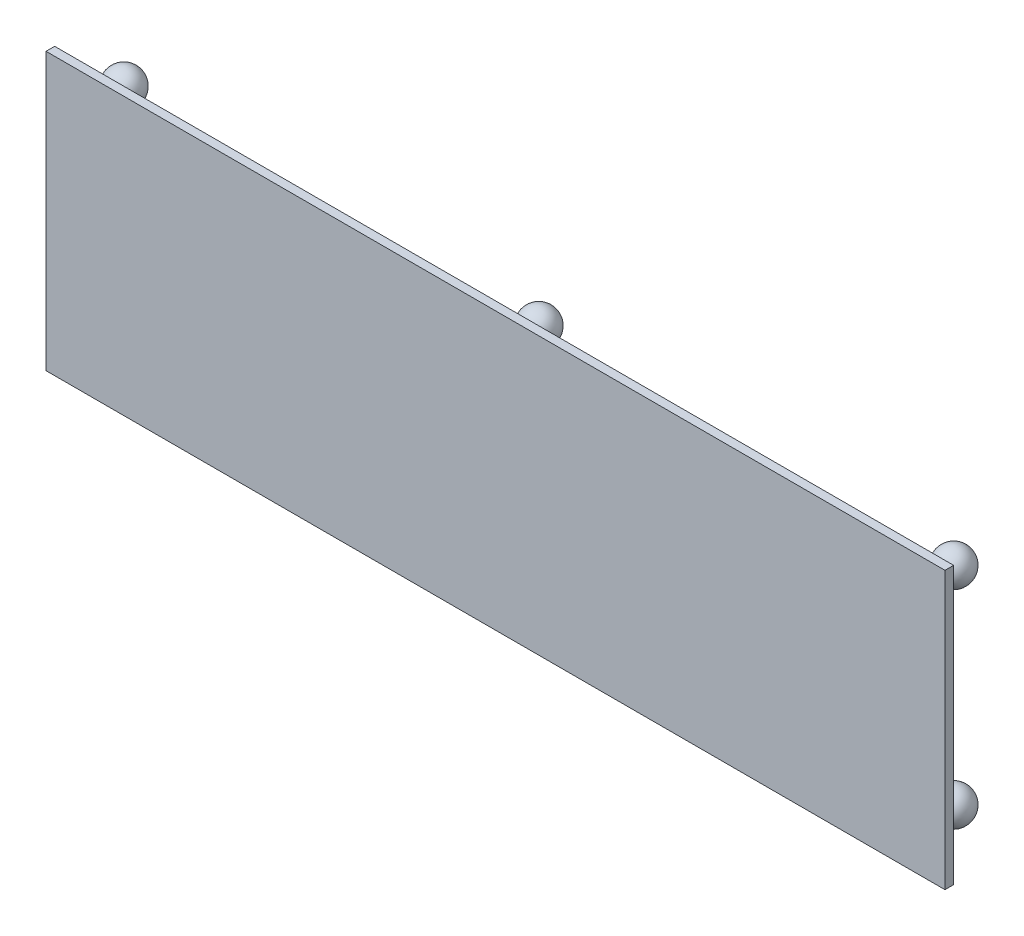
from build123d import *

# Parameters (mm, degrees)
SKETCH1_W           = 660.4
SKETCH1_H           = 203.2
BOSS_EXTRUDE1_DEPTH = 6.35
LPATTERN1_COUNT     = 2
LPATTERN1_PITCH     = 304.8
LPATTERN1_COL_COUNT = 2
LPATTERN1_COL_PITCH = 304.8


with BuildPart() as part:
    # Sketch1 → Boss-Extrude1 (new body)
    with BuildSketch(Plane.XY):
        Rectangle(SKETCH1_W, SKETCH1_H)
    extrude(amount=BOSS_EXTRUDE1_DEPTH)

    # Sketch3 → Revolve1 (revolve)
    with BuildSketch(Plane(origin=(0, 0, 0), x_dir=(0, 0, -1), z_dir=(1, 0, 0))):
        with BuildLine():
            Line((0, -76.2), (38.1, -76.2))
            ThreePointArc((38.1, -76.2), (28.44332506, -88.529970502), (14.158555499, -82.10930838))
            Line((14.158555499, -82.10930838), (0, -82.10930838))
            Line((0, -82.10930838), (0, -76.2))
        make_face()
    revolve1 = revolve(axis=Axis((0, -76.2, 0), (0, 0, -1)))

    # Mirror1: Revolve1 across plane
    add(revolve1.mirror(Plane.ZX))

    # LPattern1: Revolve1 ×2
    with Locations(*[(i * LPATTERN1_PITCH, 0, 0) for i in range(1, LPATTERN1_COUNT)]):
        add(revolve1)

    # LPattern1 copy 1 sketch → LPattern1 copy 1 (revolve)
    with BuildSketch(Plane(origin=(304.8, 0, 0), x_dir=(0, 0, -1), z_dir=(1, 0, 0))):
        with BuildLine():
            Line((0, 76.2), (38.1, 76.2))
            ThreePointArc((38.1, 76.2), (28.44332506, 88.529970502), (14.158555499, 82.10930838))
            Line((14.158555499, 82.10930838), (0, 82.10930838))
            Line((0, 82.10930838), (0, 76.2))
        make_face()
    revolve(axis=Axis((304.8, 76.2, 0), (0, 0, 1)))

    # LPattern1 col: Revolve1 ×2
    with Locations(*[(-i * LPATTERN1_COL_PITCH, 0, 0) for i in range(1, LPATTERN1_COL_COUNT)]):
        add(revolve1)

    # LPattern1 col copy 1 sketch → LPattern1 col copy 1 (revolve)
    with BuildSketch(Plane(origin=(-304.8, 0, 0), x_dir=(0, 0, -1), z_dir=(1, 0, 0))):
        with BuildLine():
            Line((0, 76.2), (38.1, 76.2))
            ThreePointArc((38.1, 76.2), (28.44332506, 88.529970502), (14.158555499, 82.10930838))
            Line((14.158555499, 82.10930838), (0, 82.10930838))
            Line((0, 82.10930838), (0, 76.2))
        make_face()
    revolve(axis=Axis((-304.8, 76.2, 0), (0, 0, 1)))


solid = part.part
